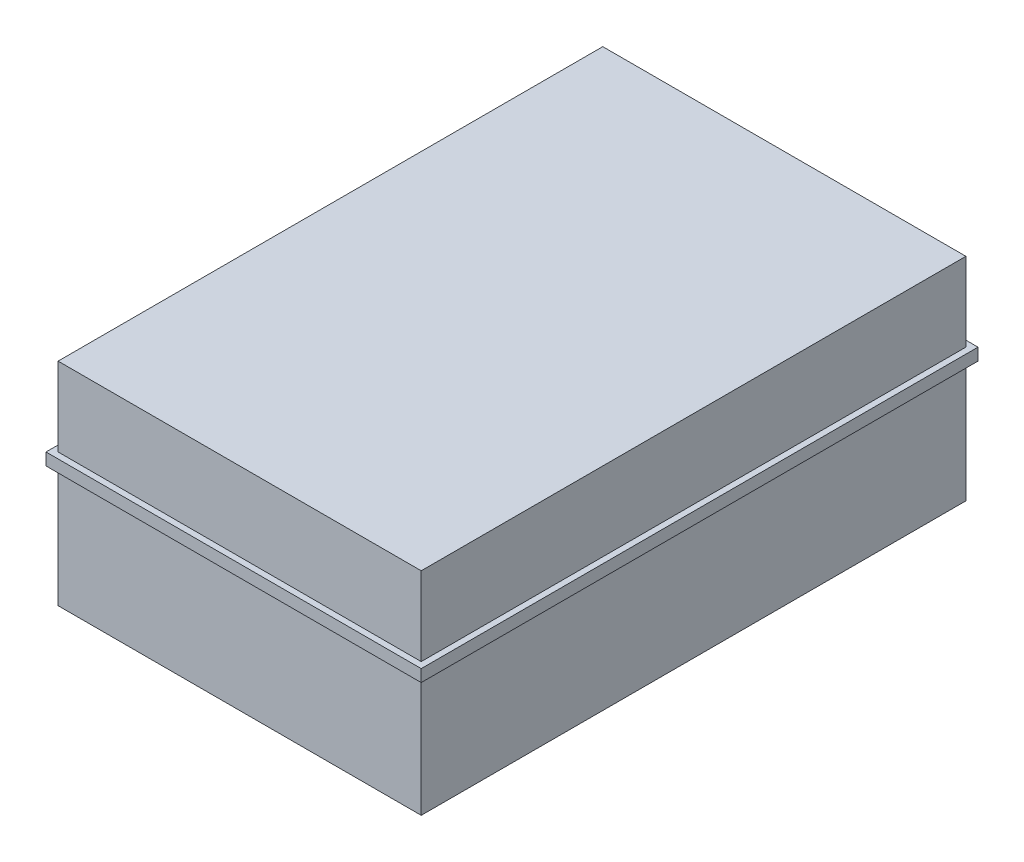
from build123d import *

# Parameters (mm, degrees)
SKETCH1_W                = 124
SKETCH1_H                = 184
SKETCH1_W_2              = 120
SKETCH1_H_2              = 180
BOSS_EXTRUDE1_DEPTH      = 4
BOSS_EXTRUDE2_DEPTH      = 30
BOSS_EXTRUDE2_DEPTH_BACK = 40
SKETCH1_3_W              = 120
SKETCH1_3_H              = 180


with BuildPart() as part:
    # Sketch1 → Boss-Extrude1 (new body)
    with BuildSketch(Plane(origin=(0, 0, 0), x_dir=(1, 0, 0), z_dir=(0, 1, 0))):
        with Locations((0, -0.402295225)):
            Rectangle(SKETCH1_W, SKETCH1_H)
        with Locations((0, -0.402295225)):
            Rectangle(SKETCH1_W_2, SKETCH1_H_2, mode=Mode.SUBTRACT)
    extrude(amount=BOSS_EXTRUDE1_DEPTH)

    # Sketch1_3 → Boss-Extrude2 (add, two sides: drawn at the far end of the back side and taken through both)
    with BuildSketch(Plane(origin=(0, 0, 0), x_dir=(1, 0, 0), z_dir=(0, 1, 0)).offset(-BOSS_EXTRUDE2_DEPTH_BACK)):
        with Locations((0, -0.402295225)):
            Rectangle(SKETCH1_3_W, SKETCH1_3_H)
    extrude(amount=BOSS_EXTRUDE2_DEPTH + BOSS_EXTRUDE2_DEPTH_BACK)


solid = part.part
